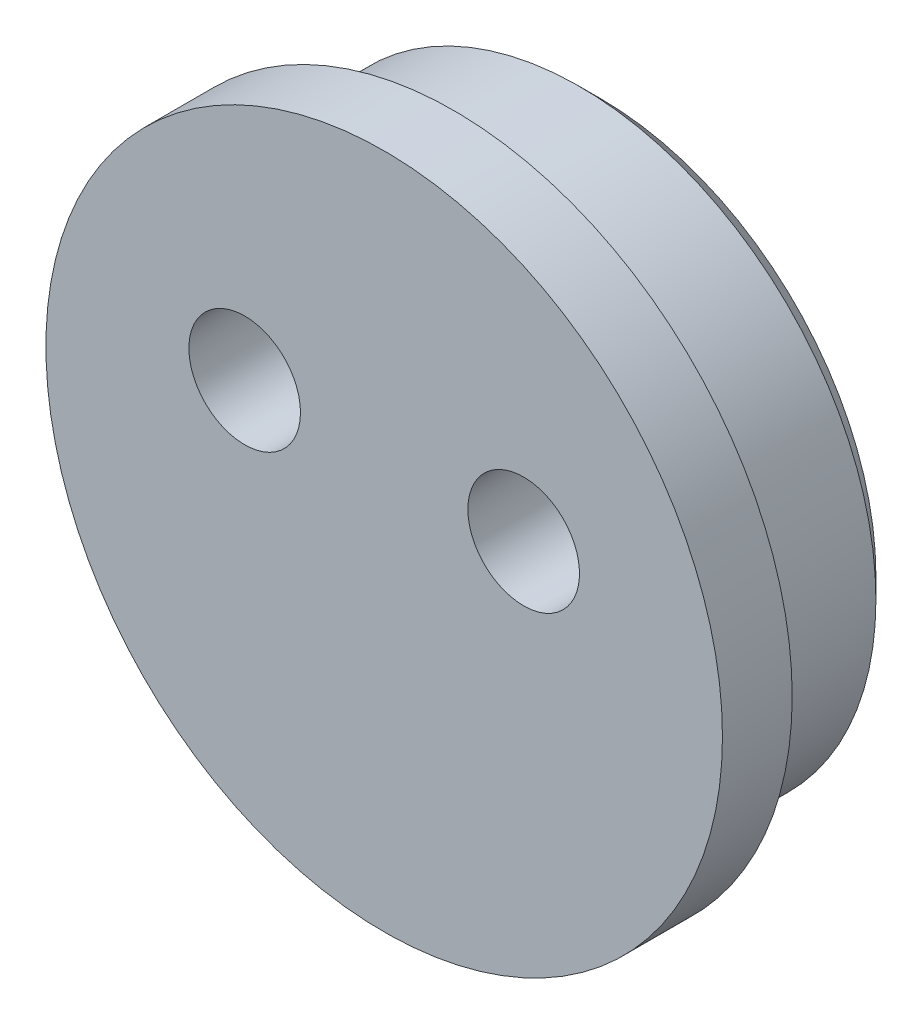
from build123d import *

# Parameters (mm, degrees)
ESQUISSE1_R        = 8.5
ESQUISSE1_R_2      = 1.6
BOSS_EXTRU_1_DEPTH = 6.2
ESQUISSE2_R        = 9.7
ESQUISSE2_R_2      = 8.5
BOSS_EXTRU_2_DEPTH = 2
CHANFREIN1_SIZE    = 0.6


with BuildPart() as part:
    # Esquisse1 → Boss.-Extru.1 (new body)
    with BuildSketch(Plane.XY):
        Circle(ESQUISSE1_R)
        with Locations((-4, 2)):
            Circle(ESQUISSE1_R_2, mode=Mode.SUBTRACT)
        with Locations((4, 2)):
            Circle(ESQUISSE1_R_2, mode=Mode.SUBTRACT)
    extrude(amount=BOSS_EXTRU_1_DEPTH)

    # Esquisse2 → Boss.-Extru.2 (add)
    with BuildSketch(Plane.XY.offset(6.2)):
        Circle(ESQUISSE2_R)
        Circle(ESQUISSE2_R_2, mode=Mode.SUBTRACT)
    extrude(amount=-BOSS_EXTRU_2_DEPTH)

    # Chanfrein1
    chanfrein1_edges = [part.edges().sort_by_distance(p)[0] for p in [
        (-8.5, 0, 0),
    ]]
    chamfer(chanfrein1_edges, length=CHANFREIN1_SIZE)


solid = part.part
